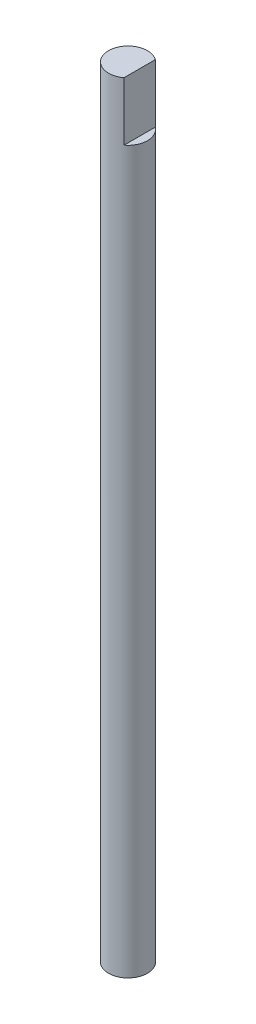
from build123d import *

# Parameters (mm, degrees)
SKETCH1_R       = 5
ROD_DEPTH       = 200
SKETCH2_W       = 2
SKETCH2_H       = 16.134958609
SLOT_DEPTH      = 6
SLOT_DEPTH_BACK = 6


with BuildPart() as part:
    # Sketch1 → Rod (new body)
    with BuildSketch(Plane(origin=(0, 0, 0), x_dir=(1, 0, 0), z_dir=(0, 1, 0))):
        Circle(SKETCH1_R)
    extrude(amount=ROD_DEPTH)

    # Sketch2 → Slot (cut, two sides)
    with BuildSketch(Plane.XY) as slot_sk:
        with Locations((4, 193.067479305)):
            Rectangle(SKETCH2_W, SKETCH2_H)
    extrude(amount=SLOT_DEPTH, mode=Mode.SUBTRACT)
    extrude(slot_sk.sketch, amount=-SLOT_DEPTH_BACK, mode=Mode.SUBTRACT)


solid = part.part
